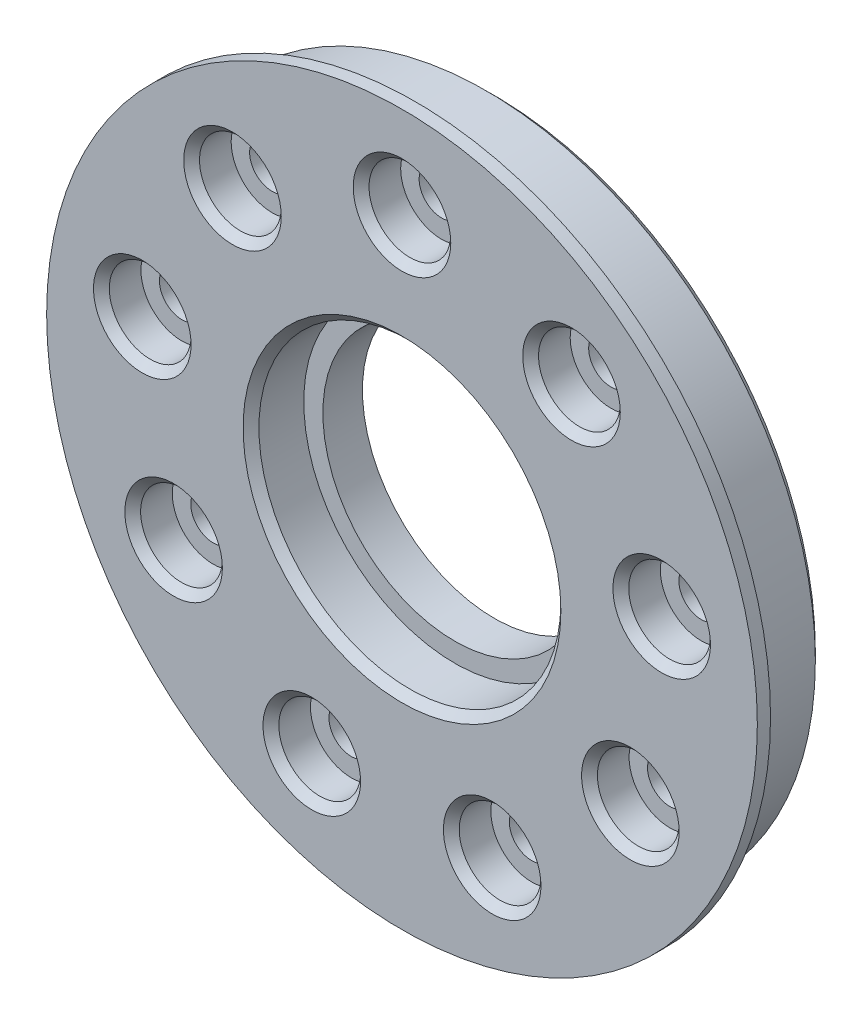
from build123d import *

# Parameters (mm, degrees)
ESQUISSE1_R             = 24.95
BOSS_EXTRU_1_DEPTH      = 6
ESQUISSE2_R             = 26.95
BOSS_EXTRU_2_DEPTH      = 1
ESQUISSE3_R             = 3.1
ENL_V_MAT_EXTRU_1_DEPTH = 3
ESQUISSE4_R             = 1.7
ENL_V_MAT_EXTRU_2_DEPTH = 8
ESQUISSE5_R             = 11.45
ENL_V_MAT_EXTRU_3_DEPTH = 4
ESQUISSE6_R             = 10
ENL_V_MAT_EXTRU_4_DEPTH = 4
CHANFREIN1_SIZE         = 0.6
CHANFREIN2_SIZE         = 0.6


with BuildPart() as part:
    # Esquisse1 → Boss.-Extru.1 (new body)
    with BuildSketch(Plane.XY):
        Circle(ESQUISSE1_R)
    extrude(amount=BOSS_EXTRU_1_DEPTH)

    # Esquisse2 → Boss.-Extru.2 (add)
    with BuildSketch(Plane.XY.offset(6)):
        Circle(ESQUISSE2_R)
    extrude(amount=BOSS_EXTRU_2_DEPTH)

    # Esquisse3 → Enlèv. mat.-Extru.1 (cut)
    with BuildSketch(Plane(origin=(0, 0, 7), x_dir=(-1, 0, 0), z_dir=(0, 0, -1))):
        with Locations((0, 20)):
            Circle(ESQUISSE3_R)
        with Locations((12.855752194, 15.320888862)):
            Circle(ESQUISSE3_R)
        with Locations((19.69615506, 3.472963553)):
            Circle(ESQUISSE3_R)
        with Locations((17.320508076, -10)):
            Circle(ESQUISSE3_R)
        with Locations((6.840402867, -18.793852416)):
            Circle(ESQUISSE3_R)
        with Locations((-6.840402867, -18.793852416)):
            Circle(ESQUISSE3_R)
        with Locations((-17.320508076, -10)):
            Circle(ESQUISSE3_R)
        with Locations((-19.69615506, 3.472963553)):
            Circle(ESQUISSE3_R)
        with Locations((-12.855752194, 15.320888862)):
            Circle(ESQUISSE3_R)
    extrude(amount=ENL_V_MAT_EXTRU_1_DEPTH, mode=Mode.SUBTRACT)

    # Esquisse4 → Enlèv. mat.-Extru.2 (cut, through all)
    with BuildSketch(Plane(origin=(0, 0, 0), x_dir=(-1, 0, 0), z_dir=(0, 0, -1))):
        with Locations((0, 20)):
            Circle(ESQUISSE4_R)
        with Locations((12.855752194, 15.320888862)):
            Circle(ESQUISSE4_R)
        with Locations((19.69615506, 3.472963553)):
            Circle(ESQUISSE4_R)
        with Locations((17.320508076, -10)):
            Circle(ESQUISSE4_R)
        with Locations((6.840402867, -18.793852416)):
            Circle(ESQUISSE4_R)
        with Locations((-6.840402867, -18.793852416)):
            Circle(ESQUISSE4_R)
        with Locations((-17.320508076, -10)):
            Circle(ESQUISSE4_R)
        with Locations((-19.69615506, 3.472963553)):
            Circle(ESQUISSE4_R)
        with Locations((-12.855752194, 15.320888862)):
            Circle(ESQUISSE4_R)
    extrude(amount=-ENL_V_MAT_EXTRU_2_DEPTH, mode=Mode.SUBTRACT)

    # Esquisse5 → Enlèv. mat.-Extru.3 (cut)
    with BuildSketch(Plane.XY.offset(7)):
        Circle(ESQUISSE5_R)
    extrude(amount=-ENL_V_MAT_EXTRU_3_DEPTH, mode=Mode.SUBTRACT)

    # Esquisse6 → Enlèv. mat.-Extru.4 (cut, through all)
    with BuildSketch(Plane.XY.offset(3)):
        Circle(ESQUISSE6_R)
    extrude(amount=-ENL_V_MAT_EXTRU_4_DEPTH, mode=Mode.SUBTRACT)

    # Chanfrein1
    chanfrein1_edges = [part.edges().sort_by_distance(p)[0] for p in [
        (3.1, 20, 7),
        (-9.755752194, 15.320888862, 7),
        (-16.59615506, 3.472963553, 7),
        (-14.220508076, -10, 7),
        (-3.740402867, -18.793852416, 7),
        (9.940402867, -18.793852416, 7),
        (20.420508076, -10, 7),
        (22.79615506, 3.472963553, 7),
        (15.955752194, 15.320888862, 7),
        (-11.45, 0, 7),
    ]]
    chamfer(chanfrein1_edges, length=CHANFREIN1_SIZE)

    # Chanfrein2
    chanfrein2_edges = [part.edges().sort_by_distance(p)[0] for p in [
        (-24.95, 0, 0),
    ]]
    chamfer(chanfrein2_edges, length=CHANFREIN2_SIZE)


solid = part.part
